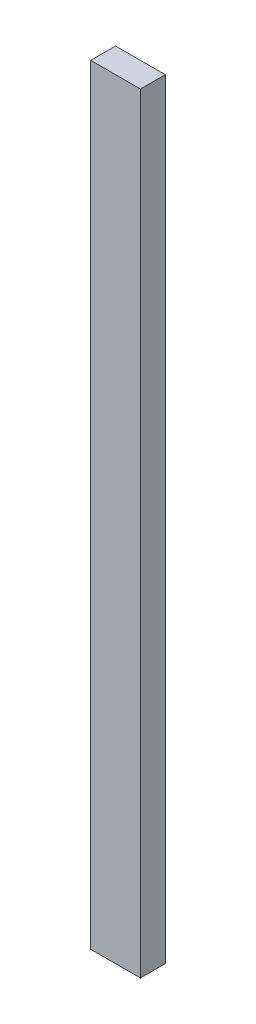
from build123d import *

# Parameters (mm, degrees)
SKETCH1_W           = 50.8
SKETCH1_H           = 25.4
BOSS_EXTRUDE1_DEPTH = 787.4


with BuildPart() as part:
    # Sketch1 → Boss-Extrude1 (new body)
    with BuildSketch(Plane(origin=(0, 0, 0), x_dir=(1, 0, 0), z_dir=(0, 1, 0))):
        with Locations((25.4, 12.7)):
            Rectangle(SKETCH1_W, SKETCH1_H)
    extrude(amount=BOSS_EXTRUDE1_DEPTH)


solid = part.part
